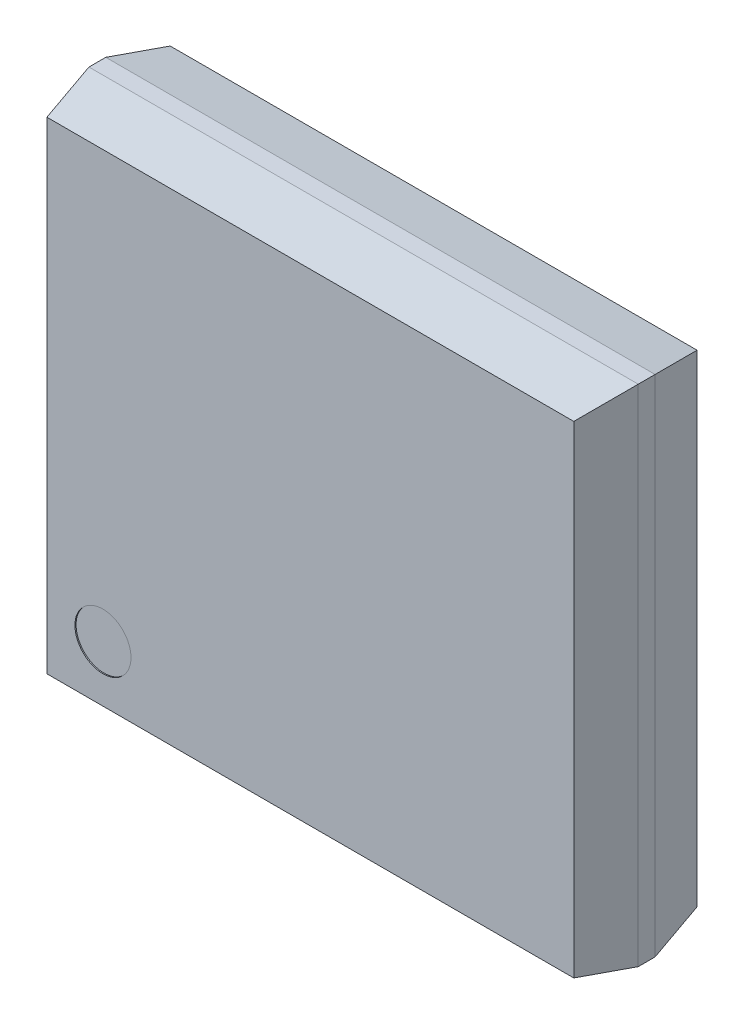
from build123d import *

# Parameters (mm, degrees)
SKETCH1_W            = 4.9
SKETCH1_H            = 4.5
BOSS_EXTRUDE1_DEPTH  = 0.55
CUT_EXTRUDE1_DEPTH   = 5.9
MIRROR2_COPY_1_DEPTH = 5.9
CUT_EXTRUDE2_DEPTH   = 5.5
MIRROR4_COPY_1_DEPTH = 5.5
SKETCH4_R            = 0.25
CUT_EXTRUDE3_DEPTH   = 0.01


with BuildPart() as part:
    # Sketch1 → Boss-Extrude1 (new body, symmetric)
    with BuildSketch(Plane.XY):
        Rectangle(SKETCH1_W, SKETCH1_H)
    extrude(amount=BOSS_EXTRUDE1_DEPTH, both=True)

    # Sketch2 → Cut-Extrude1 (cut, through all)
    with BuildSketch(Plane.ZY.offset(2.45)):
        Polygon((0.55, -2.15), (0.075, -2.25), (0.55, -2.25), align=None)
    cut_extrude1 = extrude(amount=-CUT_EXTRUDE1_DEPTH, mode=Mode.SUBTRACT)

    # Mirror1: Cut-Extrude1 across plane
    add(cut_extrude1.mirror(Plane.ZX), mode=Mode.SUBTRACT)

    # Mirror2: Cut-Extrude1 across plane
    add(cut_extrude1.mirror(Plane.XY), mode=Mode.SUBTRACT)

    # Mirror2 copy 1 sketch → Mirror2 copy 1 (cut, through all)
    with BuildSketch(Plane(origin=(-2.45, 0, 0), x_dir=(0, 0, -1), z_dir=(-1, 0, 0))):
        Polygon((0.55, -2.15), (0.075, -2.25), (0.55, -2.25), align=None)
    extrude(amount=-MIRROR2_COPY_1_DEPTH, mode=Mode.SUBTRACT)

    # Sketch3 → Cut-Extrude2 (cut, through all)
    with BuildSketch(Plane.XZ.offset(2.25)):
        Polygon((-2.45, 0.55), (-2.35, 0.55), (-2.45, 0.075), align=None)
    cut_extrude2 = extrude(amount=-CUT_EXTRUDE2_DEPTH, mode=Mode.SUBTRACT)

    # Mirror3: Cut-Extrude2 across plane
    add(cut_extrude2.mirror(Plane(origin=(0, 0, 0), x_dir=(0, 0, 1), z_dir=(1, 0, 0))), mode=Mode.SUBTRACT)

    # Mirror4: Cut-Extrude2 across plane
    add(cut_extrude2.mirror(Plane.XY), mode=Mode.SUBTRACT)

    # Mirror4 copy 1 sketch → Mirror4 copy 1 (cut, through all)
    with BuildSketch(Plane(origin=(0, -2.25, 0), x_dir=(-1, 0, 0), z_dir=(0, -1, 0))):
        Polygon((-2.45, 0.55), (-2.35, 0.55), (-2.45, 0.075), align=None)
    extrude(amount=-MIRROR4_COPY_1_DEPTH, mode=Mode.SUBTRACT)

    # Sketch4 → Cut-Extrude3 (cut)
    with BuildSketch(Plane.XY.offset(0.55)):
        with Locations((-1.85, -1.65)):
            Circle(SKETCH4_R)
    extrude(amount=-CUT_EXTRUDE3_DEPTH, mode=Mode.SUBTRACT)


solid = part.part
